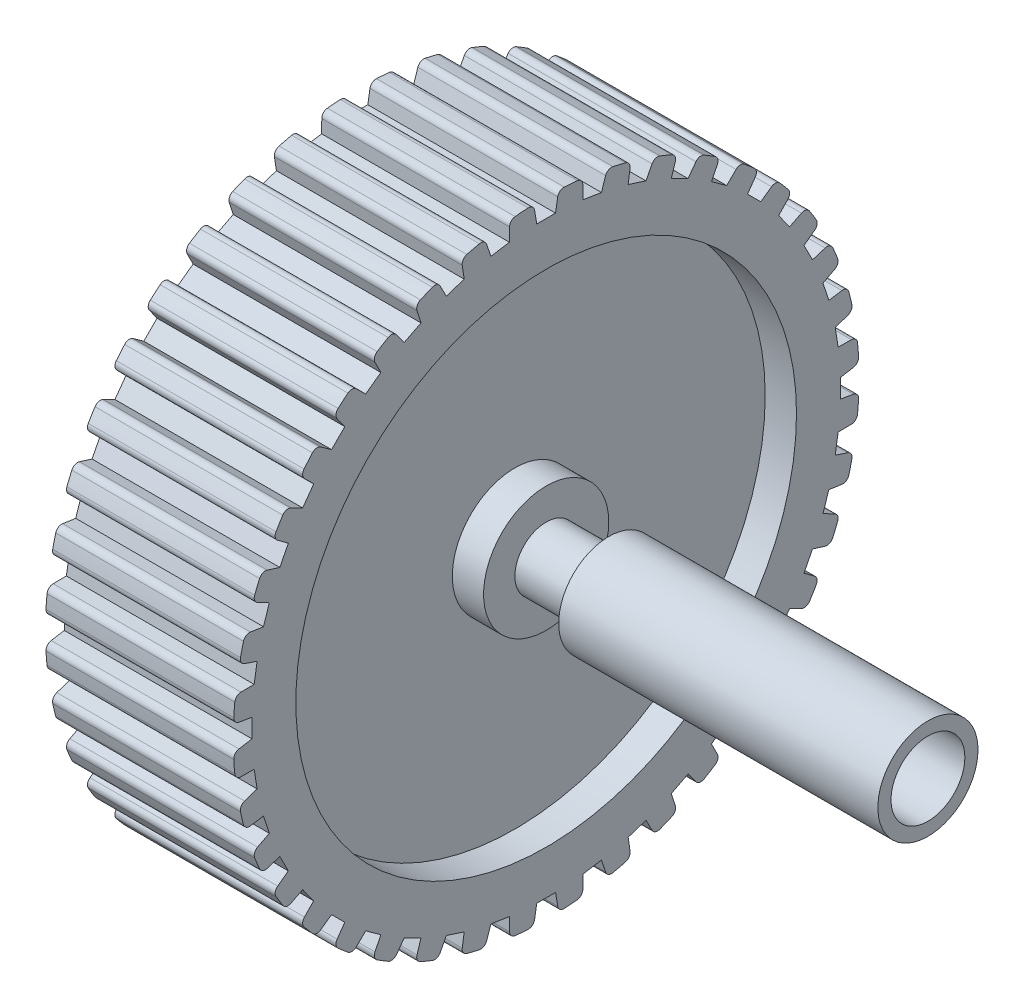
from build123d import *

# Parameters (mm, degrees)
CUT_EXTRUDE1_DEPTH       = 44
FILLET1_R                = 1
CIRPATTERN1_COUNT        = 40
FILLET1_OF_CIRPATTERN1_R = 1
SCALE1_SCALE             = 0.5
SKETCH3_R                = 2.5
BOSS_EXTRUDE1_DEPTH      = 30
SKETCH4_R                = 4
BOSS_EXTRUDE2_DEPTH      = 15.5
BOSS_EXTRUDE2_DEPTH_BACK = 10
SKETCH5_R                = 2.95
CUT_EXTRUDE2_DEPTH       = 15.5


with BuildPart() as part:
    # Sketch1 → Revolve1 (revolve)
    with BuildSketch(Plane.XY):
        Polygon((0, 5), (-30, 5), (-30, 10), (-25, 10), (-25, 40), (-30, 40), (-30, 50), (0, 50), (0, 40), (-5, 40), (-5, 10), (0, 10), align=None)
    revolve(axis=Axis((0, 0, 0), (-1, 0, 0)))

    # Sketch2 → Cut-Extrude1 (cut)
    with BuildSketch(Plane(origin=(0, 0, 0), x_dir=(0, 0, -1), z_dir=(1, 0, 0))):
        Polygon((-2.5, 53), (-1.5, 47), (1.5, 47), (2.5, 53), align=None)
    cut_extrude1 = extrude(amount=-CUT_EXTRUDE1_DEPTH, mode=Mode.SUBTRACT)

    # Fillet1
    fillet1_edges = [part.edges().sort_by_distance(p)[0] for p in [
        (-15, 49.960248768, -1.993374795),
        (-15, 49.960248768, 1.993374795),
    ]]
    fillet(fillet1_edges, radius=FILLET1_R)

    # CirPattern1: Cut-Extrude1 ×40 about axis
    cirpattern1_axis = Axis((0, 0, 0), (1, 0, 0))
    for i in range(1, CIRPATTERN1_COUNT):
        add(cut_extrude1.rotate(cirpattern1_axis, i * 360 / CIRPATTERN1_COUNT), mode=Mode.SUBTRACT)

    # Fillet1 of CirPattern1
    fillet1_of_cirpattern1_edges = [part.edges().sort_by_distance(p)[0] for p in [
        (-15, 49.656987721, 5.846671746),
        (-15, 49.033322681, 9.784337832),
        (-15, 48.131006834, 13.542753825),
        (-15, 46.899033459, 17.334378),
        (-15, 45.419880821, 20.905368358),
        (-15, 43.609934383, 24.457588252),
        (-15, 41.590366603, 27.753223342),
        (-15, 39.24701399, 30.978571512),
        (-15, 36.736759528, 33.917701859),
        (-15, 33.917701859, 36.736759528),
        (-15, 30.978571512, 39.24701399),
        (-15, 27.753223342, 41.590366603),
        (-15, 24.457588252, 43.609934383),
        (-15, 20.905368358, 45.419880821),
        (-15, 17.334378, 46.899033459),
        (-15, 13.542753825, 48.131006834),
        (-15, 9.784337832, 49.033322681),
        (-15, 5.846671746, 49.656987721),
        (-15, 1.993374795, 49.960248768),
        (-15, -1.993374795, 49.960248768),
        (-15, -5.846671746, 49.656987721),
        (-15, -9.784337832, 49.033322681),
        (-15, -13.542753825, 48.131006834),
        (-15, -17.334378, 46.899033459),
        (-15, -20.905368358, 45.419880821),
        (-15, -24.457588252, 43.609934383),
        (-15, -27.753223342, 41.590366603),
        (-15, -30.978571512, 39.24701399),
        (-15, -33.917701859, 36.736759528),
        (-15, -36.736759528, 33.917701859),
        (-15, -39.24701399, 30.978571512),
        (-15, -41.590366603, 27.753223342),
        (-15, -43.609934383, 24.457588252),
        (-15, -45.419880821, 20.905368358),
        (-15, -46.899033459, 17.334378),
        (-15, -48.131006834, 13.542753825),
        (-15, -49.033322681, 9.784337832),
        (-15, -49.656987721, 5.846671746),
        (-15, -49.960248768, 1.993374795),
        (-15, -49.960248768, -1.993374795),
        (-15, -49.656987721, -5.846671746),
        (-15, -49.033322681, -9.784337832),
        (-15, -48.131006834, -13.542753825),
        (-15, -46.899033459, -17.334378),
        (-15, -45.419880821, -20.905368358),
        (-15, -43.609934383, -24.457588252),
        (-15, -41.590366603, -27.753223342),
        (-15, -39.24701399, -30.978571512),
        (-15, -36.736759528, -33.917701859),
        (-15, -33.917701859, -36.736759528),
        (-15, -30.978571512, -39.24701399),
        (-15, -27.753223342, -41.590366603),
        (-15, -24.457588252, -43.609934383),
        (-15, -20.905368358, -45.419880821),
        (-15, -17.334378, -46.899033459),
        (-15, -13.542753825, -48.131006834),
        (-15, -9.784337832, -49.033322681),
        (-15, -5.846671746, -49.656987721),
        (-15, -1.993374795, -49.960248768),
        (-15, 1.993374795, -49.960248768),
        (-15, 5.846671746, -49.656987721),
        (-15, 9.784337832, -49.033322681),
        (-15, 13.542753825, -48.131006834),
        (-15, 17.334378, -46.899033459),
        (-15, 20.905368358, -45.419880821),
        (-15, 24.457588252, -43.609934383),
        (-15, 27.753223342, -41.590366603),
        (-15, 30.978571512, -39.24701399),
        (-15, 33.917701859, -36.736759528),
        (-15, 36.736759528, -33.917701859),
        (-15, 39.24701399, -30.978571512),
        (-15, 41.590366603, -27.753223342),
        (-15, 43.609934383, -24.457588252),
        (-15, 45.419880821, -20.905368358),
        (-15, 46.899033459, -17.334378),
        (-15, 48.131006834, -13.542753825),
        (-15, 49.033322681, -9.784337832),
        (-15, 49.656987721, -5.846671746),
    ]]
    fillet(fillet1_of_cirpattern1_edges, radius=FILLET1_OF_CIRPATTERN1_R)


with BuildPart() as part_1:
    # Scale1: scaled about (-15, 0, 0)
    add(part.part.scale(SCALE1_SCALE).moved(Location((-7.5, 0, 0))))

    # Sketch3 → Boss-Extrude1 (add)
    with BuildSketch(Plane.ZY.offset(22.5)):
        Circle(SKETCH3_R)
    extrude(amount=-BOSS_EXTRUDE1_DEPTH)

    # Sketch4 → Boss-Extrude2 (add, two sides)
    with BuildSketch(Plane(origin=(7.5, 0, 0), x_dir=(0, 0, -1), z_dir=(1, 0, 0))) as boss_extrude2_sk:
        Circle(SKETCH4_R)
    extrude(amount=BOSS_EXTRUDE2_DEPTH)
    extrude(boss_extrude2_sk.sketch, amount=-BOSS_EXTRUDE2_DEPTH_BACK)

    # Sketch5 → Cut-Extrude2 (cut)
    with BuildSketch(Plane(origin=(23, 0, 0), x_dir=(0, 0, -1), z_dir=(1, 0, 0))):
        Circle(SKETCH5_R)
    extrude(amount=-CUT_EXTRUDE2_DEPTH, mode=Mode.SUBTRACT)


solid = part_1.part
